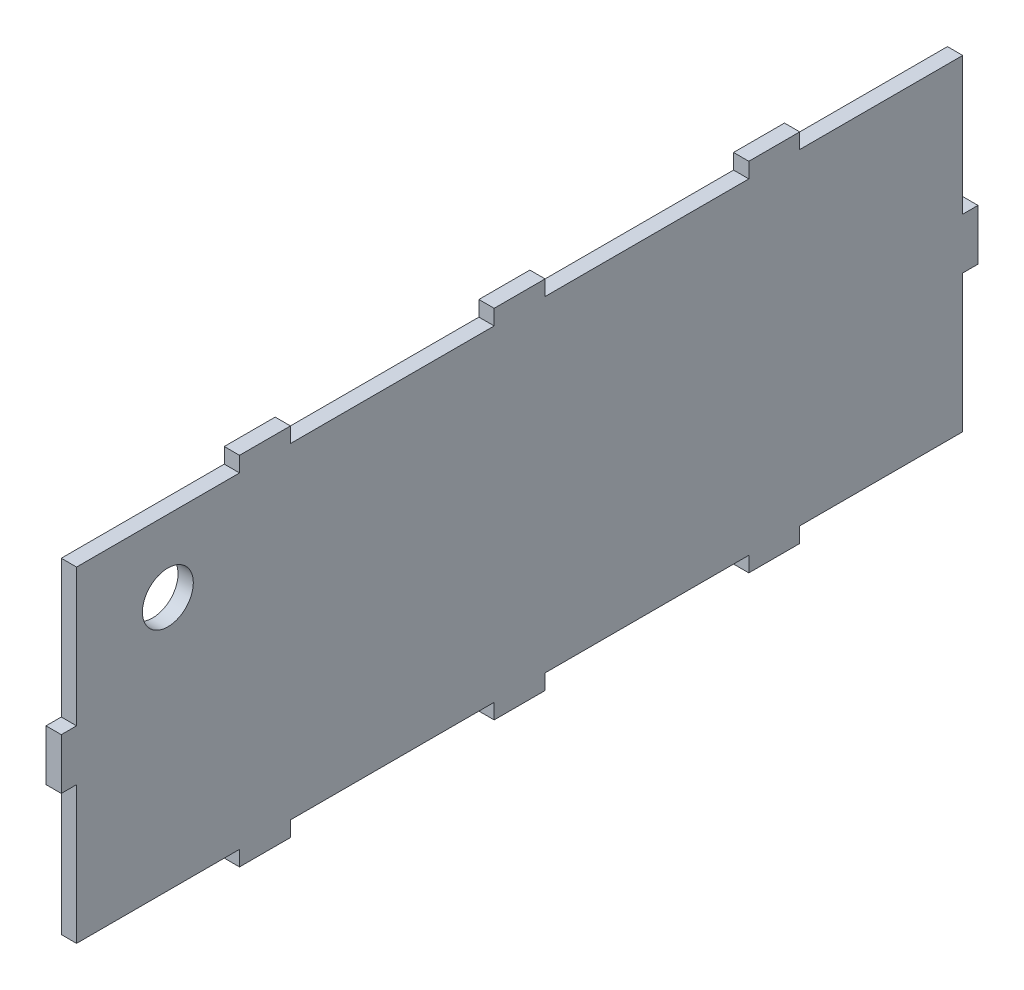
from build123d import *

# Parameters (mm, degrees)
SKETCH1_W           = 180
SKETCH1_H           = 70
BOSS_EXTRUDE1_DEPTH = 3
SKETCH2_W           = 3
SKETCH2_H           = 27
SKETCH2_W_2         = 40
SKETCH2_H_2         = 3
CUT_EXTRUDE6_DEPTH  = 10
SKETCH3_R           = 5
CUT_EXTRUDE7_DEPTH  = 12


with BuildPart() as part:
    # Sketch1 → Boss-Extrude1 (new body)
    with BuildSketch(Plane(origin=(0, 0, 0), x_dir=(0, 0, -1), z_dir=(1, 0, 0))):
        Rectangle(SKETCH1_W, SKETCH1_H)
    extrude(amount=BOSS_EXTRUDE1_DEPTH)

    # Sketch2 → Cut-Extrude6 (cut)
    with BuildSketch(Plane(origin=(3, 0, 0), x_dir=(0, 0, -1), z_dir=(1, 0, 0))):
        Polygon((90, -32), (87, -32), (55, -32), (55, -35), (90, -35), align=None)
        with Locations((88.5, -18.5)):
            Rectangle(SKETCH2_W, SKETCH2_H)
        with Locations((25, -33.5)):
            Rectangle(SKETCH2_W_2, SKETCH2_H_2)
        with Locations((-25, -33.5)):
            Rectangle(SKETCH2_W_2, SKETCH2_H_2)
        Polygon((-55, -32), (-87, -32), (-90, -32), (-90, -35), (-55, -35), align=None)
        with Locations((-88.5, -18.5)):
            Rectangle(SKETCH2_W, SKETCH2_H)
        with Locations((-88.5, 18.5)):
            Rectangle(SKETCH2_W, SKETCH2_H)
        Polygon((-87, 32), (-55, 32), (-55, 35), (-90, 35), (-90, 32), align=None)
        with Locations((-25, 33.5)):
            Rectangle(SKETCH2_W_2, SKETCH2_H_2)
        with Locations((25, 33.5)):
            Rectangle(SKETCH2_W_2, SKETCH2_H_2)
        Polygon((55, 32), (87, 32), (90, 32), (90, 35), (55, 35), align=None)
        with Locations((88.5, 18.5)):
            Rectangle(SKETCH2_W, SKETCH2_H)
    extrude(amount=-CUT_EXTRUDE6_DEPTH, mode=Mode.SUBTRACT)

    # Sketch3 → Cut-Extrude7 (cut)
    with BuildSketch(Plane(origin=(3, 0, 0), x_dir=(0, 0, -1), z_dir=(1, 0, 0))):
        with Locations((-69.072414396, 17.873185396)):
            Circle(SKETCH3_R)
    extrude(amount=-CUT_EXTRUDE7_DEPTH, mode=Mode.SUBTRACT)


solid = part.part
